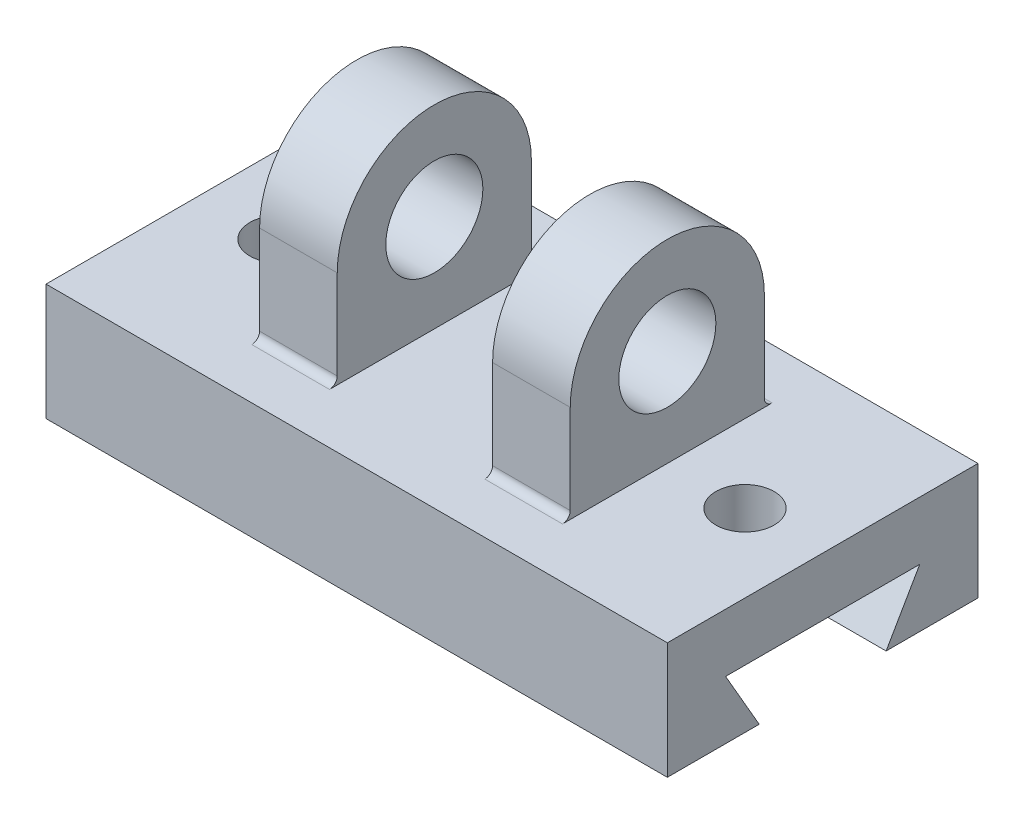
from build123d import *

# Parameters (mm, degrees)
BOSS_EXTRUDE1_DEPTH = 80
SKETCH4_W           = 20
SKETCH4_H           = 50
BOSS_EXTRUDE2_DEPTH = 50
SKETCH5_R           = 7.5
CUT_EXTRUDE2_DEPTH  = 15
CUT_EXTRUDE3_DEPTH  = 40
CUT_EXTRUDE4_DEPTH  = 40
SKETCH13_R          = 12.5
CUT_EXTRUDE5_DEPTH  = 40
CUT_EXTRUDE6_DEPTH  = 20
FILLET1_R           = 2


with BuildPart() as part:
    # Sketch1 → Boss-Extrude1 (new body)
    with BuildSketch(Plane(origin=(0, 0, 0), x_dir=(0, 0, -1), z_dir=(1, 0, 0))):
        Polygon((-65, -15), (-15, -15), (-23.660254038, -30), (0, -30), (0, 0), (-80, 0), (-80, -30), (-56.339745962, -30), align=None)
    boss_extrude1 = extrude(amount=BOSS_EXTRUDE1_DEPTH)

    # Sketch4 → Boss-Extrude2 (add)
    with BuildSketch(Plane(origin=(0, 0, 0), x_dir=(1, 0, 0), z_dir=(0, 1, 0))):
        with Locations((30, -40)):
            Rectangle(SKETCH4_W, SKETCH4_H)
    boss_extrude2 = extrude(amount=BOSS_EXTRUDE2_DEPTH)

    # Sketch5 → Cut-Extrude2 (cut)
    with BuildSketch(Plane(origin=(0, 0, 0), x_dir=(1, 0, 0), z_dir=(0, 1, 0))):
        with Locations((60, -40)):
            Circle(SKETCH5_R)
    cut_extrude2 = extrude(amount=-CUT_EXTRUDE2_DEPTH, mode=Mode.SUBTRACT)

    # Sketch9 → Cut-Extrude3 (cut)
    with BuildSketch(Plane(origin=(0, 0, 0), x_dir=(0, 0, -1), z_dir=(1, 0, 0))):
        with BuildLine():
            Line((-65, 25), (-65, 50))
            Line((-65, 50), (-40, 50))
            ThreePointArc((-40, 50), (-57.67766953, 42.67766953), (-65, 25))
        make_face()
    cut_extrude3 = extrude(amount=CUT_EXTRUDE3_DEPTH, mode=Mode.SUBTRACT)

    # Sketch11 → Cut-Extrude4 (cut)
    with BuildSketch(Plane(origin=(0, 0, 0), x_dir=(0, 0, -1), z_dir=(1, 0, 0))):
        with BuildLine():
            Line((-15, 25), (-15, 50))
            Line((-15, 50), (-40, 50))
            ThreePointArc((-40, 50), (-22.32233047, 42.67766953), (-15, 25))
        make_face()
    extrude(amount=CUT_EXTRUDE4_DEPTH, mode=Mode.SUBTRACT)

    # Sketch13 → Cut-Extrude5 (cut)
    with BuildSketch(Plane(origin=(0, 0, 0), x_dir=(0, 0, -1), z_dir=(1, 0, 0))):
        with Locations((-40, 25)):
            Circle(SKETCH13_R)
    cut_extrude5 = extrude(amount=CUT_EXTRUDE5_DEPTH, mode=Mode.SUBTRACT)

    # Mirror3: Boss-Extrude1, Boss-Extrude2, Cut-Extrude2, Cut-Extrude3, Cut-Extrude5 across plane
    add(boss_extrude1.mirror(Plane(origin=(0, 0, 0), x_dir=(0, 0, 1), z_dir=(1, 0, 0))))
    add(boss_extrude2.mirror(Plane(origin=(0, 0, 0), x_dir=(0, 0, 1), z_dir=(1, 0, 0))))
    add(cut_extrude2.mirror(Plane(origin=(0, 0, 0), x_dir=(0, 0, 1), z_dir=(1, 0, 0))), mode=Mode.SUBTRACT)
    add(cut_extrude3.mirror(Plane(origin=(0, 0, 0), x_dir=(0, 0, 1), z_dir=(1, 0, 0))), mode=Mode.SUBTRACT)
    add(cut_extrude5.mirror(Plane(origin=(0, 0, 0), x_dir=(0, 0, 1), z_dir=(1, 0, 0))), mode=Mode.SUBTRACT)

    # Sketch17 → Cut-Extrude6 (cut)
    with BuildSketch(Plane(origin=(-20, 0, 0), x_dir=(0, 0, -1), z_dir=(1, 0, 0))):
        with BuildLine():
            Line((-40, 50), (-15, 50))
            Line((-15, 50), (-15, 25))
            ThreePointArc((-15, 25), (-22.32233047, 42.67766953), (-40, 50))
        make_face()
    extrude(amount=-CUT_EXTRUDE6_DEPTH, mode=Mode.SUBTRACT)

    # Fillet1
    fillet1_edges = [part.edges().sort_by_distance(p)[0] for p in [
        (-30, 0, 65),
        (-30, 0, 15),
        (30, 0, 65),
        (30, 0, 15),
    ]]
    fillet(fillet1_edges, radius=FILLET1_R)


solid = part.part
